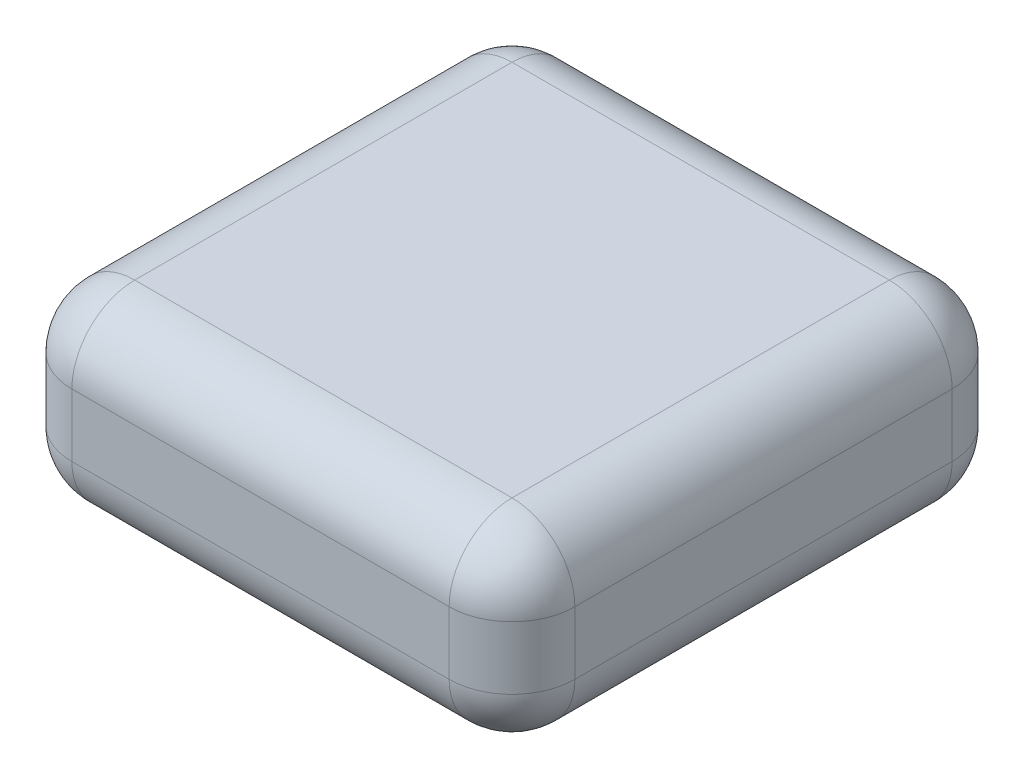
from build123d import *

# Parameters (mm, degrees)
SKETCH1_W           = 1219.2
SKETCH1_H           = 1219.2
BOSS_EXTRUDE1_DEPTH = 457.2
FILLET1_R           = 152.4


with BuildPart() as part:
    # Sketch1 → Boss-Extrude1 (new body)
    with BuildSketch(Plane(origin=(0, 0, 0), x_dir=(1, 0, 0), z_dir=(0, 1, 0))):
        Rectangle(SKETCH1_W, SKETCH1_H)
    extrude(amount=BOSS_EXTRUDE1_DEPTH)

    # Fillet1
    fillet1_edges = [part.edges().sort_by_distance(p)[0] for p in [
        (-609.6, 457.2, 0),
        (0, 457.2, 609.6),
        (609.6, 457.2, 0),
        (0, 0, 609.6),
        (-609.6, 0, 0),
        (0, 0, -609.6),
        (609.6, 0, 0),
        (609.6, 228.6, 609.6),
        (-609.6, 228.6, 609.6),
        (-609.6, 228.6, -609.6),
        (609.6, 228.6, -609.6),
        (0, 457.2, -609.6),
    ]]
    fillet(fillet1_edges, radius=FILLET1_R)


solid = part.part
